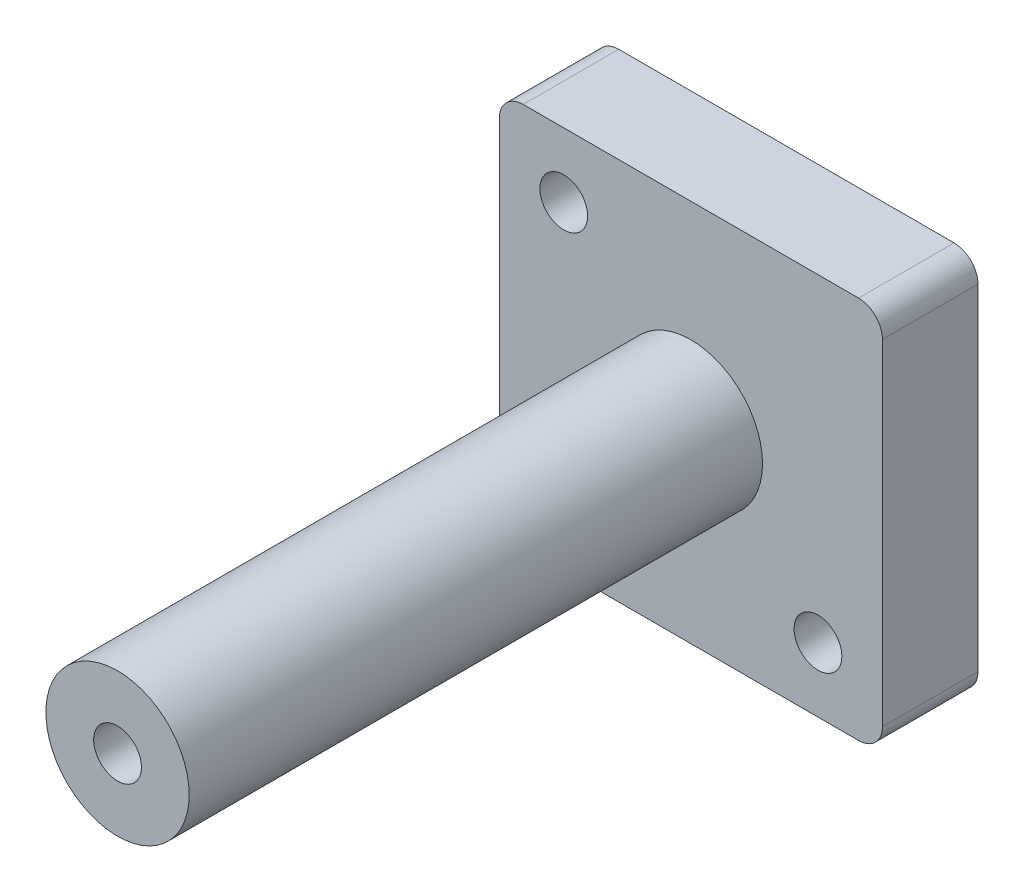
from build123d import *

# Parameters (mm, degrees)
SKETCH1_R           = 2.5
BOSS_EXTRUDE1_DEPTH = 10
SKETCH2_R           = 7.5
BOSS_EXTRUDE2_DEPTH = 60
SKETCH3_R           = 2.5
CUT_EXTRUDE1_DEPTH  = 15


with BuildPart() as part:
    # Sketch1 → Boss-Extrude1 (new body)
    with BuildSketch(Plane.XY):
        with BuildLine():
            Line((2.5, 0), (37.6, 0))
            ThreePointArc((37.6, 0), (39.367766953, 0.732233047), (40.1, 2.5))
            Line((40.1, 2.5), (40.1, 37.6))
            ThreePointArc((40.1, 37.6), (39.367766953, 39.367766953), (37.6, 40.1))
            Line((37.6, 40.1), (2.5, 40.1))
            ThreePointArc((2.5, 40.1), (0.732233047, 39.367766953), (0, 37.6))
            Line((0, 37.6), (0, 2.5))
            ThreePointArc((0, 2.5), (0.732233047, 0.732233047), (2.5, 0))
        make_face()
        with Locations((6.75, 33.35)):
            Circle(SKETCH1_R, mode=Mode.SUBTRACT)
        with Locations((33.35, 6.75)):
            Circle(SKETCH1_R, mode=Mode.SUBTRACT)
    extrude(amount=BOSS_EXTRUDE1_DEPTH)

    # Sketch2 → Boss-Extrude2 (add)
    with BuildSketch(Plane.XY.offset(10)):
        with Locations((20.05, 20.05)):
            Circle(SKETCH2_R)
    extrude(amount=BOSS_EXTRUDE2_DEPTH)

    # Sketch3 → Cut-Extrude1 (cut)
    with BuildSketch(Plane.XY.offset(70)):
        with Locations((20.05, 20.05)):
            Circle(SKETCH3_R)
    extrude(amount=-CUT_EXTRUDE1_DEPTH, mode=Mode.SUBTRACT)


solid = part.part
